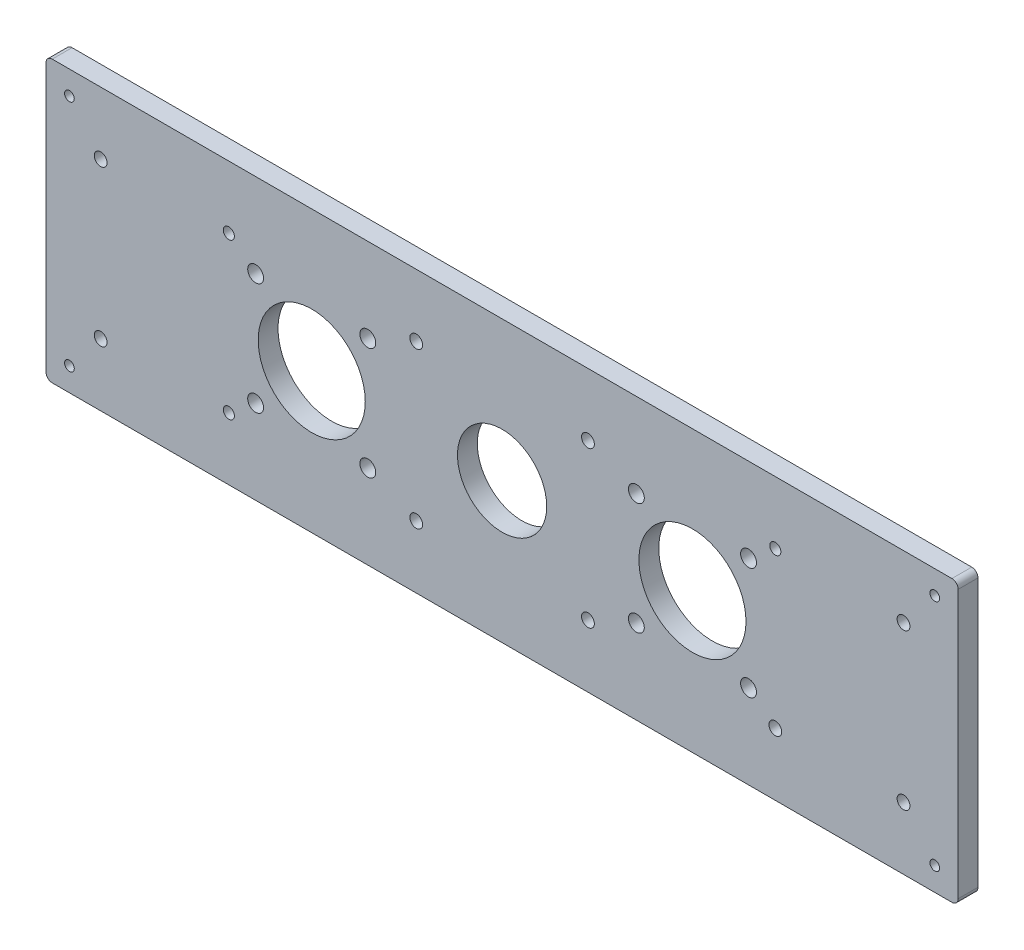
from build123d import *

# Parameters (mm, degrees)
SKETCH1_W           = 292.1
SKETCH1_H           = 89.8
SKETCH1_R           = 14.2875
SKETCH1_R_2         = 2.54
SKETCH1_R_3         = 17.145
BOSS_EXTRUDE1_DEPTH = 6.35
SKETCH2_R           = 2.05
CUT_EXTRUDE1_DEPTH  = 10
SKETCH3_R           = 1.55
SKETCH3_R_2         = 2.05
CUT_EXTRUDE2_DEPTH  = 10
FILLET1_R           = 2
SKETCH4_R           = 2.05
SKETCH4_R_2         = 1.778
CUT_EXTRUDE4_DEPTH  = 7.35


with BuildPart() as part:
    # Sketch1 → Boss-Extrude1 (new body)
    with BuildSketch(Plane.XY):
        with Locations((146.05, 44.9)):
            Rectangle(SKETCH1_W, SKETCH1_H)
        with Locations((146.05, 44.9)):
            Circle(SKETCH1_R, mode=Mode.SUBTRACT)
        with Locations((103.051585406, 62.859439014)):
            Circle(SKETCH1_R_2, mode=Mode.SUBTRACT)
        with Locations((103.049439014, 26.938414594)):
            Circle(SKETCH1_R_2, mode=Mode.SUBTRACT)
        with Locations((67.128414594, 26.940560986)):
            Circle(SKETCH1_R_2, mode=Mode.SUBTRACT)
        with Locations((67.130560986, 62.861585406)):
            Circle(SKETCH1_R_2, mode=Mode.SUBTRACT)
        with Locations((85.09, 44.9)):
            Circle(SKETCH1_R_3, mode=Mode.SUBTRACT)
        with Locations((189.050560986, 62.861585406)):
            Circle(SKETCH1_R_2, mode=Mode.SUBTRACT)
        with Locations((224.971585406, 62.859439014)):
            Circle(SKETCH1_R_2, mode=Mode.SUBTRACT)
        with Locations((224.969439014, 26.938414594)):
            Circle(SKETCH1_R_2, mode=Mode.SUBTRACT)
        with Locations((189.048414594, 26.940560986)):
            Circle(SKETCH1_R_2, mode=Mode.SUBTRACT)
        with Locations((207.01, 44.9)):
            Circle(SKETCH1_R_3, mode=Mode.SUBTRACT)
    extrude(amount=BOSS_EXTRUDE1_DEPTH)

    # Sketch2 → Cut-Extrude1 (cut)
    with BuildSketch(Plane.XY.offset(6.35)):
        with Locations((118.55, 20)):
            Circle(SKETCH2_R)
        with Locations((118.55, 69.8)):
            Circle(SKETCH2_R)
        with Locations((173.55, 20)):
            Circle(SKETCH2_R)
        with Locations((173.55, 69.8)):
            Circle(SKETCH2_R)
    extrude(amount=-CUT_EXTRUDE1_DEPTH, mode=Mode.SUBTRACT)

    # Sketch3 → Cut-Extrude2 (cut)
    with BuildSketch(Plane.XY.offset(6.35)):
        with Locations((284.6, 7.5)):
            Circle(SKETCH3_R)
        with Locations((7.5, 7.5)):
            Circle(SKETCH3_R)
        with Locations((7.5, 82.3)):
            Circle(SKETCH3_R)
        with Locations((284.6, 82.3)):
            Circle(SKETCH3_R)
        with Locations((274.6, 20)):
            Circle(SKETCH3_R_2)
        with Locations((17.5, 20)):
            Circle(SKETCH3_R_2)
        with Locations((17.5, 69.8)):
            Circle(SKETCH3_R_2)
        with Locations((274.6, 69.8)):
            Circle(SKETCH3_R_2)
    extrude(amount=-CUT_EXTRUDE2_DEPTH, mode=Mode.SUBTRACT)

    # Fillet1
    fillet1_edges = [part.edges().sort_by_distance(p)[0] for p in [
        (0, 89.8, 3.175),
        (292.1, 89.8, 3.175),
        (292.1, 0, 3.175),
        (0, 0, 3.175),
    ]]
    fillet(fillet1_edges, radius=FILLET1_R)

    # Sketch4 → Cut-Extrude4 (cut, through all)
    with BuildSketch(Plane.XY.offset(6.35)):
        with Locations((233.55, 20)):
            Circle(SKETCH4_R)
        with Locations((233.55, 69.8)):
            Circle(SKETCH4_R_2)
        with Locations((58.55, 69.8)):
            Circle(SKETCH4_R_2)
        with Locations((58.55, 20)):
            Circle(SKETCH4_R_2)
    extrude(amount=-CUT_EXTRUDE4_DEPTH, mode=Mode.SUBTRACT)


solid = part.part
